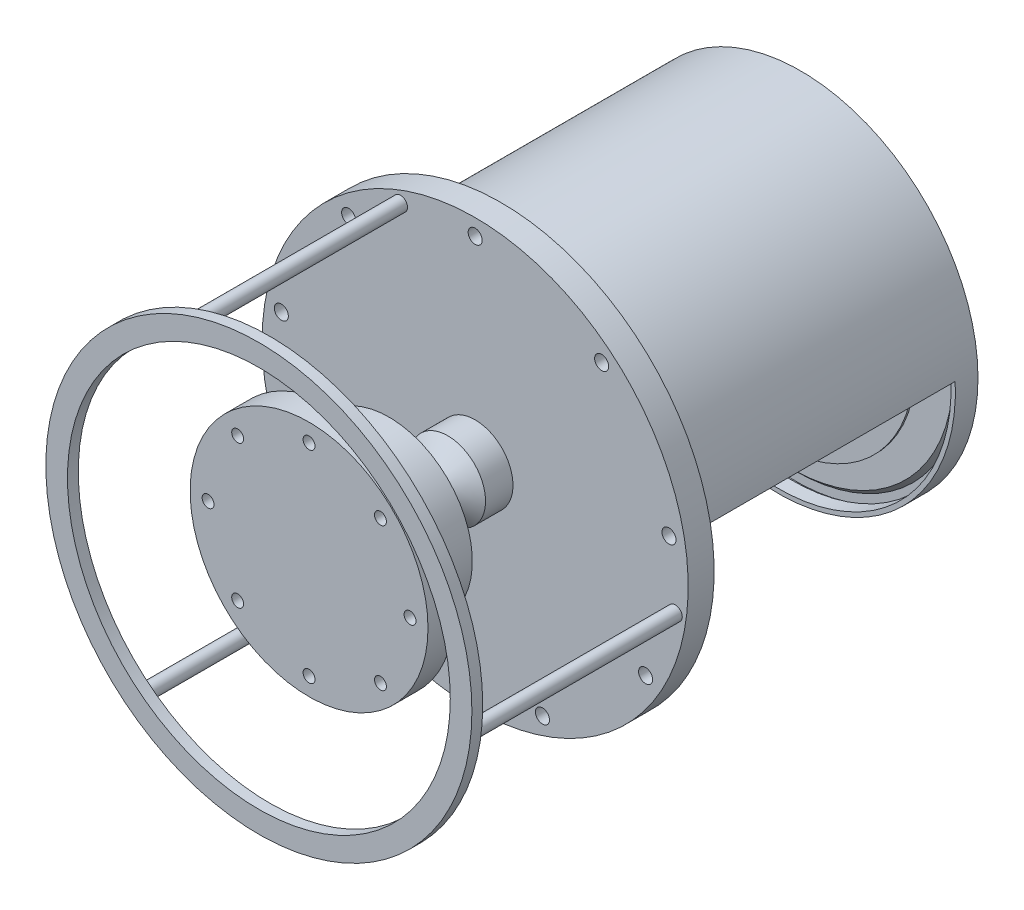
from build123d import *

# Parameters (mm, degrees)
SKETCH_14_W         = 110
SKETCH_14_H         = 12
SKETCH_9136_R       = 6.5
CUT_EXTRUDE_2_DEPTH = 34
SKETCH_24_R         = 5.5
CUT_EXTRUDE_3_DEPTH = 24
SKETCH_26_R         = 6.5
EXTRUDE_1_DEPTH     = 190
SKETCH_27_R         = 197
SKETCH_27_R_2       = 177
EXTRUDE_2_DEPTH     = 10
SKETCH_28_W         = 656.385241422
SKETCH_28_H         = 232.103468141
CUT_EXTRUDE_4_DEPTH = 250


with BuildPart() as part:
    # Эскиз14 → Повернуть11 (revolve)
    with BuildSketch(Plane(origin=(0, 0, 0), x_dir=(1, 0, 0), z_dir=(0, 1, 0))):
        with Locations((-55, -447)):
            Rectangle(SKETCH_14_W, SKETCH_14_H)
    revolve(axis=Axis((0, 0, 600), (0, 0, -1)))

    # Эскиз15 → Повернуть12 (revolve)
    with BuildSketch(Plane(origin=(0, 0, 0), x_dir=(1, 0, 0), z_dir=(0, 1, 0))):
        Polygon((-110, -441), (-110, -429), (-77, -429), (-77, -379), (-15, -379), (-15, -381), (-75, -381), (-75, -441), align=None)
    revolve(axis=Axis((0, 0, 0), (0, 0, 1)))

    # Эскиз16 → Повернуть17 (revolve)
    with BuildSketch(Plane(origin=(0, 0, 0), x_dir=(1, 0, 0), z_dir=(0, 1, 0))):
        Polygon((-15, -381), (-13, -381), (-13, -332.5), (-11.5, -332.5), (-11.5, -304.5), (-18.2, -304.5), (-17.3, -307.5), (-15.7, -307.5), (-15, -305.5), (-13, -305.5), (-13, -331), (-15, -331), align=None)
    revolve(axis=Axis((0, 0, 0), (0, 0, 1)))

    # Эскиз17 → Повернуть19 (revolve)
    with BuildSketch(Plane(origin=(0, 0, 0), x_dir=(1, 0, 0), z_dir=(0, 1, 0))):
        Polygon((-16.5, -341), (-15, -341), (-15, -336.62), (-33.5, -323.4), (-33.5, -283.4), (-159.5, -283.4), (-159.5, -287.4), (-197, -287.4), (-197, -299.4), (-35, -299.4), (-35, -324.78), (-16.5, -338), align=None)
    revolve(axis=Axis((0, 0, 0), (0, 0, 1)))

    # Эскиз18 → Повернуть20 (revolve)
    with BuildSketch(Plane(origin=(0, 0, 0), x_dir=(1, 0, 0), z_dir=(0, 1, 0))):
        Polygon((-197, -287.4), (-197, -275.4), (-170, -275.4), (-170, -277.4), (-166, -277.4), (-166, -275.4), (-164, -275.4), (-164, 1.6), (-162, 1.6), (-162, -6.4), (-160, -6.4), (-160, -287.4), (-165, -287.4), (-165, -282.4), (-170, -282.4), (-170, -287.4), align=None)
    revolve(axis=Axis((0, 0, 0), (0, 0, 1)))

    # Эскиз19 → Повернуть21 (revolve)
    with BuildSketch(Plane(origin=(0, 0, 0), x_dir=(1, 0, 0), z_dir=(0, 1, 0))):
        Polygon((-162, 1.6), (-160, 1.6), (-160, -0.4), (-157, -0.4), (-157, 1.6), (-64.5, 1.6), (-64.5, -0.4), (-61.5, -0.4), (-61.5, 1.6), (-59.5, 1.6), (-59.5, -0.4), (-56.5, -0.4), (-56.5, 1.6), (-30.5, 1.6), (-25.5, -6.4), (-25.5, -7.4), (-150, -7.4), (-154, -3.4), (-162, -3.4), align=None)
    revolve(axis=Axis((0, 0, 0), (0, 0, 1)))

    # Sketch 9136 → Вырез-Вытянуть2 (cut)
    with BuildSketch(Plane(origin=(0, 0, 275.4), x_dir=(-1, 0, 0), z_dir=(0, 0, -1))):
        with Locations((0, 182)):
            Circle(SKETCH_9136_R)
        with Locations((116.987344963, 139.420088648)):
            Circle(SKETCH_9136_R)
        with Locations((179.235011048, 31.603968335)):
            Circle(SKETCH_9136_R)
        with Locations((157.616623489, -91)):
            Circle(SKETCH_9136_R)
        with Locations((62.247666085, -171.024056983)):
            Circle(SKETCH_9136_R)
        with Locations((-62.247666085, -171.024056983)):
            Circle(SKETCH_9136_R)
        with Locations((-157.616623489, -91)):
            Circle(SKETCH_9136_R)
        with Locations((-179.235011048, 31.603968335)):
            Circle(SKETCH_9136_R)
        with Locations((-116.987344963, 139.420088648)):
            Circle(SKETCH_9136_R)
    extrude(amount=-CUT_EXTRUDE_2_DEPTH, mode=Mode.SUBTRACT)

    # Эскиз24 → Вырез-Вытянуть3 (cut)
    with BuildSketch(Plane.XY.offset(453)):
        with Locations((0, 93.393216605)):
            Circle(SKETCH_24_R)
        with Locations((66.038976778, 66.038976778)):
            Circle(SKETCH_24_R)
        with Locations((93.393216605, 0)):
            Circle(SKETCH_24_R)
        with Locations((66.038976778, -66.038976778)):
            Circle(SKETCH_24_R)
        with Locations((0, -93.393216605)):
            Circle(SKETCH_24_R)
        with Locations((-66.038976778, -66.038976778)):
            Circle(SKETCH_24_R)
        with Locations((-93.393216605, 0)):
            Circle(SKETCH_24_R)
        with Locations((-66.038976778, 66.038976778)):
            Circle(SKETCH_24_R)
    extrude(amount=-CUT_EXTRUDE_3_DEPTH, mode=Mode.SUBTRACT)

    # Эскиз26 → Бобышка-Вытянуть1 (add)
    with BuildSketch(Plane.XY.offset(299.4)):
        with Locations((-115.975838416, -146.692211462)):
            Circle(SKETCH_26_R)
        with Locations((-69.051262455, 173.784128025)):
            Circle(SKETCH_26_R)
        with Locations((185.027100872, -27.091916563)):
            Circle(SKETCH_26_R)
    extrude(amount=EXTRUDE_1_DEPTH)

    # Эскиз27 → Бобышка-Вытянуть2 (add)
    with BuildSketch(Plane.XY.offset(489.4)):
        Circle(SKETCH_27_R)
        Circle(SKETCH_27_R_2, mode=Mode.SUBTRACT)
    extrude(amount=EXTRUDE_2_DEPTH)


with BuildPart() as body_2:
    # Эскиз20 → Повернуть22 (revolve)
    with BuildSketch(Plane(origin=(0, 0, 0), x_dir=(1, 0, 0), z_dir=(0, 1, 0))):
        Polygon((-156.5, -243.4), (-12.5, -243.4), (-12.5, -227.4), (-14.5, -227.4), (-14.5, -229.4), (-16.5, -229.4), (-16.5, -227.4), (-119.5, -227.4), (-119.5, -233.4), (-130.5, -233.4), (-130.5, -230.4), (-136.5, -230.4), (-136.5, -233.4), (-156.5, -233.4), align=None)
    revolve(axis=Axis((0, 0, 0), (0, 0, 1)))

    # Эскиз21 → Повернуть26 (revolve)
    with BuildSketch(Plane(origin=(0, 0, 0), x_dir=(1, 0, 0), z_dir=(0, 1, 0))):
        Polygon((-18.2, -251), (-10.2, -251), (-10.2, -227.4), (-12.5, -227.4), (-12.5, -250), (-15.03, -250), (-15.7, -247.5), (-17.3, -247.5), align=None)
        Polygon((-19.5, -301.5), (-17, -301.5), (-18.479019946, -300.5), (-17.003480047, -299.907647059), (-18.479019946, -298.91), (-17.003480047, -298.317647059), (-18.479019946, -297.32), (-17.003480047, -296.727647059), (-18.479019946, -295.73), (-17.003480047, -295.137647059), (-18.479019946, -294.14), (-17.003480047, -293.547647059), (-18.479019946, -292.55), (-17.003480047, -291.957647059), (-18.479019946, -290.96), (-17.003480047, -290.367647059), (-18.479019946, -289.37), (-17.003480047, -288.777647059), (-18.479019946, -287.78), (-17.003480047, -287.187647059), (-18.479019946, -286.19), (-17.003480047, -285.597647059), (-18.479019946, -284.6), (-17.003480047, -284.007647059), (-18.479019946, -283.01), (-17.003480047, -282.417647059), (-18.479019946, -281.42), (-17.003480047, -280.827647059), (-18.479019946, -279.83), (-17.003480047, -279.237647059), (-18.479019946, -278.24), (-17.003480047, -277.647647059), (-18.479019946, -276.65), (-17.003480047, -276.057647059), (-18.479019946, -275.06), (-17.003480047, -274.467647059), (-18.479019946, -273.47), (-17.003480047, -272.877647059), (-18.479019946, -271.88), (-17.003480047, -271.287647059), (-18.479019946, -270.29), (-17.003480047, -269.697647059), (-18.479019946, -268.7), (-17.003480047, -268.107647059), (-18.479019946, -267.11), (-17.003480047, -266.517647059), (-18.479019946, -265.52), (-17.003480047, -264.927647059), (-18.479019946, -263.93), (-17.003480047, -263.337647059), (-18.479019946, -262.34), (-17.003480047, -261.747647059), (-18.479019946, -260.75), (-17.003480047, -260.157647059), (-18.479019946, -259.16), (-17.003480047, -258.567647059), (-18.479019946, -257.57), (-17.003480047, -256.977647059), (-18.479019946, -255.98), (-17.003480047, -255.387647059), (-18.479019946, -254.39), (-17, -253.79625), (-17, -253.5), (-19.5, -253.5), align=None)
    revolve(axis=Axis((0, 0, 0), (0, 0, 1)))

    # Эскиз22 → Повернуть27 (revolve)
    with BuildSketch(Plane(origin=(0, 0, 0), x_dir=(1, 0, 0), z_dir=(0, 1, 0))):
        Polygon((-156.5, -232.4), (-136.5, -232.4), (-136.5, -230.4), (-130.819984699, -230.4), (-130.819984699, -224.4), (-127.559984699, -224.4), (-123.9, -229.4), (-120.5, -229.4), (-120.5, -20.9), (-121.75, -20.9), (-121.75, -19.4), (-123.5, -19.4), (-123.5, -216.4), (-156.5, -216.4), align=None)
    revolve(axis=Axis((0, 0, 0), (0, 0, 1)))

    # Эскиз23 → Revolve 9094 (revolve)
    with BuildSketch(Plane(origin=(0, 0, 0), x_dir=(1, 0, 0), z_dir=(0, 1, 0))):
        Polygon((-125.5, -204.4), (-125.5, -17.4), (0, -17.4), (0, -19.4), (-123.5, -19.4), (-123.5, -204.4), align=None)
    revolve(axis=Axis((0, 0, 0), (0, 0, 1)))


with BuildPart() as cut_extrude_4_tool:
    # Эскиз28 → Вырез-Вытянуть4 (new body)
    with BuildSketch(Plane(origin=(0.50521912, -2.871359923, -1.6), x_dir=(0.997936519, 0.064208292, 0), z_dir=(-0.064208292, 0.997936519, 0))):
        with Locations((61.785092491, -136.932352181)):
            Rectangle(SKETCH_28_W, SKETCH_28_H)
    extrude(amount=-CUT_EXTRUDE_4_DEPTH)


with BuildPart() as part_1:
    add(part.part)

    # Вырез-Вытянуть4: cut by cut_extrude_4_tool
    add(cut_extrude_4_tool.part, mode=Mode.SUBTRACT)


with BuildPart() as body_2_1:
    add(body_2.part)

    # Вырез-Вытянуть4: cut by cut_extrude_4_tool
    add(cut_extrude_4_tool.part, mode=Mode.SUBTRACT)


solid = Compound([part_1.part, body_2_1.part])
